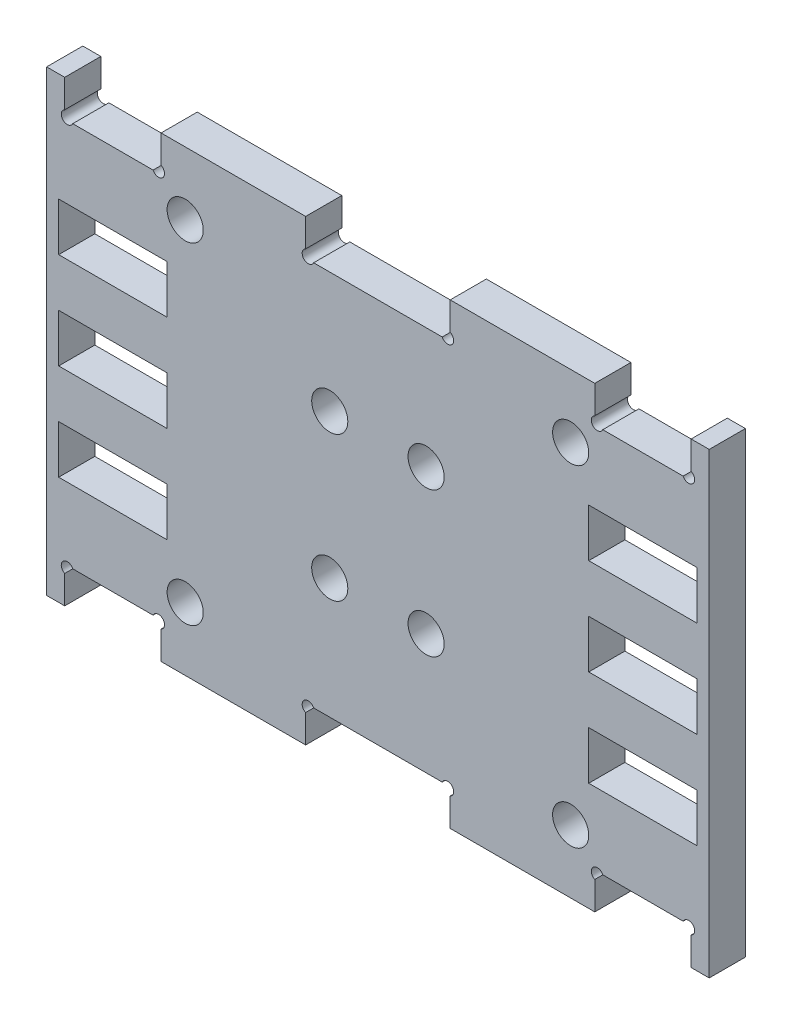
from build123d import *

# Parameters (mm, degrees)
SKETCH_1_W          = 55
SKETCH_1_H          = 38
EXTRUDE_1_DEPTH     = 3
SKETCH_2_R          = 1.5
CUT_EXTRUDE_1_DEPTH = 30
SKETCH_3_W          = 8
SKETCH_3_H          = 3
CUT_EXTRUDE_2_DEPTH = 30
SKETCH_5_W          = 12
SKETCH_5_H          = 3
CUT_EXTRUDE_4_DEPTH = 10
SKETCH_6_W          = 9
SKETCH_6_H          = 4
CUT_EXTRUDE_5_DEPTH = 10
SKETCH_7_R          = 0.5
CUT_EXTRUDE_6_DEPTH = 10
CUT_EXTRUDE_7_DEPTH = 20


with BuildPart() as part:
    # 草图1 → 凸台-拉伸1 (new body)
    with BuildSketch(Plane.XY):
        Rectangle(SKETCH_1_W, SKETCH_1_H)
    extrude(amount=EXTRUDE_1_DEPTH)

    # 草图2 → 切除-拉伸1 (cut)
    with BuildSketch(Plane.XY.offset(3)):
        with Locations((16, 13.75)):
            Circle(SKETCH_2_R)
        with Locations((16, -13.75)):
            Circle(SKETCH_2_R)
        with Locations((-16, 13.75)):
            Circle(SKETCH_2_R)
        with Locations((-16, -13.75)):
            Circle(SKETCH_2_R)
    extrude(amount=-CUT_EXTRUDE_1_DEPTH, mode=Mode.SUBTRACT)

    # 草图3 → 切除-拉伸2 (cut)
    with BuildSketch(Plane.XY.offset(3)):
        with Locations((22, 17.5)):
            Rectangle(SKETCH_3_W, SKETCH_3_H)
        with Locations((22, -17.5)):
            Rectangle(SKETCH_3_W, SKETCH_3_H)
        with Locations((-22, 17.5)):
            Rectangle(SKETCH_3_W, SKETCH_3_H)
        with Locations((-22, -17.5)):
            Rectangle(SKETCH_3_W, SKETCH_3_H)
    extrude(amount=-CUT_EXTRUDE_2_DEPTH, mode=Mode.SUBTRACT)

    # 草图5 → 切除-拉伸4 (cut)
    with BuildSketch(Plane.XY.offset(3)):
        with Locations((0, -17.5)):
            Rectangle(SKETCH_5_W, SKETCH_5_H)
        with Locations((0, 17.5)):
            Rectangle(SKETCH_5_W, SKETCH_5_H)
    extrude(amount=-CUT_EXTRUDE_4_DEPTH, mode=Mode.SUBTRACT)

    # 草图6 → 切除-拉伸5 (cut)
    with BuildSketch(Plane(origin=(0, 0, 0), x_dir=(-1, 0, 0), z_dir=(0, 0, -1))):
        with Locations((-22, -8)):
            Rectangle(SKETCH_6_W, SKETCH_6_H)
        with Locations((-22, 0)):
            Rectangle(SKETCH_6_W, SKETCH_6_H)
        with Locations((-22, 8)):
            Rectangle(SKETCH_6_W, SKETCH_6_H)
        with Locations((22, -8)):
            Rectangle(SKETCH_6_W, SKETCH_6_H)
        with Locations((22, 0)):
            Rectangle(SKETCH_6_W, SKETCH_6_H)
        with Locations((22, 8)):
            Rectangle(SKETCH_6_W, SKETCH_6_H)
    extrude(amount=-CUT_EXTRUDE_5_DEPTH, mode=Mode.SUBTRACT)

    # 草图7 → 切除-拉伸6 (cut)
    with BuildSketch(Plane(origin=(0, 0, 0), x_dir=(-1, 0, 0), z_dir=(0, 0, -1))):
        with Locations((-18.212132034, -16.212132034)):
            Circle(SKETCH_7_R)
        with Locations((-25.787867966, -16.212132034)):
            Circle(SKETCH_7_R)
        with Locations((-25.787867966, 16.212132034)):
            Circle(SKETCH_7_R)
        with Locations((-18.212132034, 16.212132034)):
            Circle(SKETCH_7_R)
        with Locations((-5.787867966, -16.212132034)):
            Circle(SKETCH_7_R)
        with Locations((25.787867966, -16.212132034)):
            Circle(SKETCH_7_R)
        with Locations((18.212132034, -16.212132034)):
            Circle(SKETCH_7_R)
        with Locations((18.212132034, 16.212132034)):
            Circle(SKETCH_7_R)
        with Locations((25.787867966, 16.212132034)):
            Circle(SKETCH_7_R)
        with Locations((-5.787867966, 16.212132034)):
            Circle(SKETCH_7_R)
        with Locations((5.787867966, 16.212132034)):
            Circle(SKETCH_7_R)
        with Locations((5.787867966, -16.212132034)):
            Circle(SKETCH_7_R)
    extrude(amount=-CUT_EXTRUDE_6_DEPTH, mode=Mode.SUBTRACT)

    # 草图8 → 切除-拉伸7 (cut)
    with BuildSketch(Plane(origin=(0, 0, 0), x_dir=(-1, 0, 0), z_dir=(0, 0, -1))):
        with BuildLine():
            ThreePointArc((-2.5, 6), (-5.060660172, 7.060660172), (-4, 4.5))
            Line((-4, 4.5), (-4, 6))
            Line((-4, 6), (-2.5, 6))
        make_face()
        with BuildLine():
            Line((-4, 6), (-4, 4.5))
            ThreePointArc((-4, 4.5), (-2.939339828, 4.939339828), (-2.5, 6))
            Line((-2.5, 6), (-4, 6))
        make_face()
        with BuildLine():
            ThreePointArc((2.5, 6), (2.939339828, 4.939339828), (4, 4.5))
            Line((4, 4.5), (4, 6))
            Line((4, 6), (2.5, 6))
        make_face()
        with BuildLine():
            Line((4, 6), (4, 4.5))
            ThreePointArc((4, 4.5), (5.060660172, 4.939339828), (5.5, 6))
            ThreePointArc((5.5, 6), (4, 7.5), (2.5, 6))
            Line((2.5, 6), (4, 6))
        make_face()
        with BuildLine():
            ThreePointArc((5.5, -6), (5.060660172, -4.939339828), (4, -4.5))
            Line((4, -4.5), (4, -6))
            Line((4, -6), (2.5, -6))
            ThreePointArc((2.5, -6), (4, -7.5), (5.5, -6))
        make_face()
        with BuildLine():
            Line((4, -6), (4, -4.5))
            ThreePointArc((4, -4.5), (2.939339828, -4.939339828), (2.5, -6))
            Line((2.5, -6), (4, -6))
        make_face()
        with BuildLine():
            ThreePointArc((-2.5, -6), (-2.939339828, -4.939339828), (-4, -4.5))
            Line((-4, -4.5), (-4, -6))
            Line((-4, -6), (-2.5, -6))
        make_face()
        with BuildLine():
            Line((-4, -6), (-4, -4.5))
            ThreePointArc((-4, -4.5), (-5.060660172, -7.060660172), (-2.5, -6))
            Line((-2.5, -6), (-4, -6))
        make_face()
    extrude(amount=-CUT_EXTRUDE_7_DEPTH, mode=Mode.SUBTRACT)


solid = part.part
